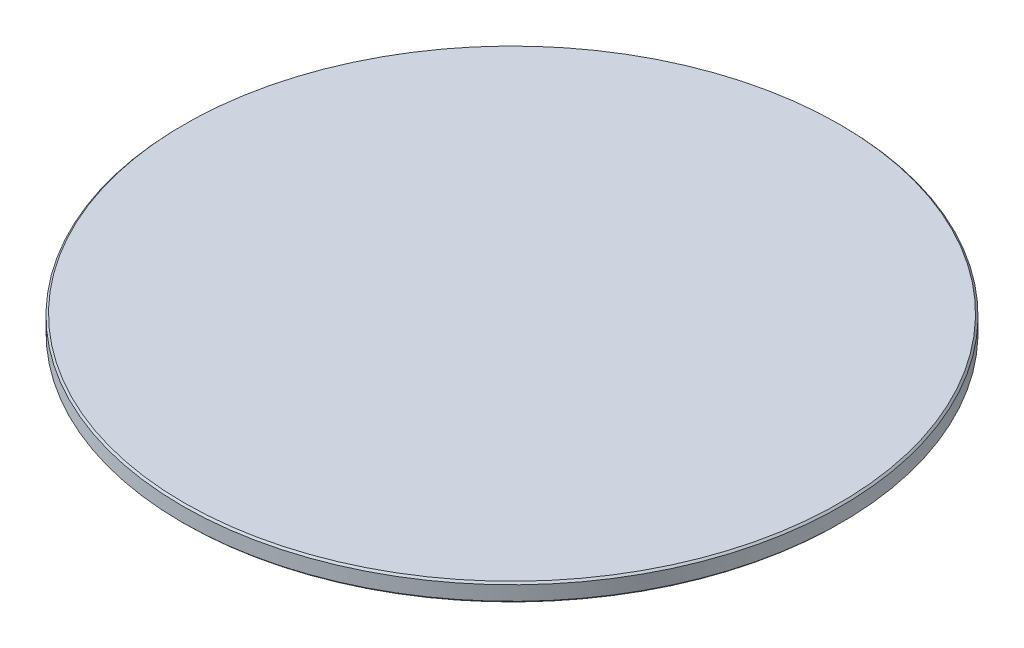
from build123d import *

# Parameters (mm, degrees)
CHAMFER1_SIZE = 0.5


with BuildPart() as part:
    # Sketch1 → Revolve1 (revolve)
    with BuildSketch(Plane.XY):
        Polygon((0, 0), (92, 0), (92, -5), (90.1, -5), (90.1, -2), (84.9, -2), (84.9, -5), (83, -5), (83, -1.2), (0, -1.2), align=None)
    revolve(axis=Axis((0, -1.2, 0), (0, 1, 0)))

    # Chamfer1
    chamfer1_edges = [part.edges().sort_by_distance(p)[0] for p in [
        (-92, -5, 0),
        (-92, 0, 0),
        (-83, -1.2, 0),
        (-83, -5, 0),
        (-84.9, -5, 0),
        (-90.1, -5, 0),
    ]]
    chamfer(chamfer1_edges, length=CHAMFER1_SIZE)


solid = part.part
